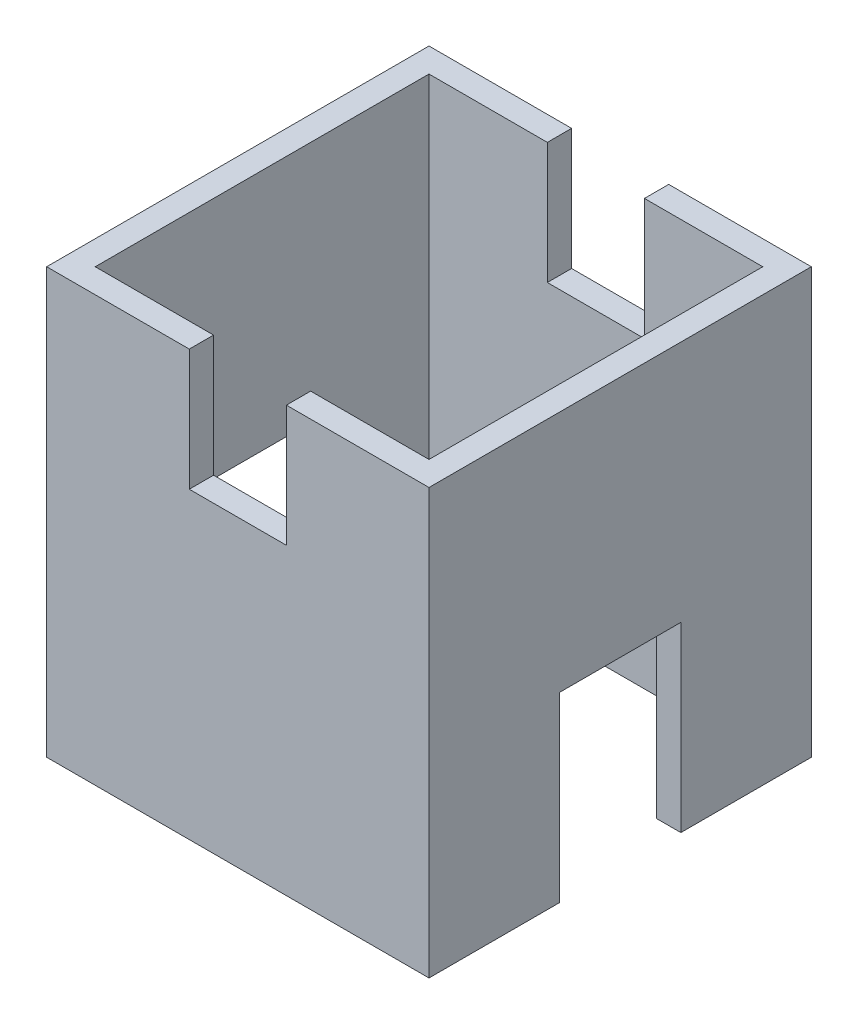
from build123d import *

# Parameters (mm, degrees)
SKETCH1_W           = 31.5
SKETCH1_H           = 31.5
SKETCH1_W_2         = 27.5
SKETCH1_H_2         = 27.5
BOSS_EXTRUDE1_DEPTH = 35
SKETCH2_W           = 10
SKETCH2_H           = 15
CUT_EXTRUDE1_DEPTH  = 32.5
SKETCH3_W           = 8
SKETCH3_H           = 10
CUT_EXTRUDE2_DEPTH  = 32.5


with BuildPart() as part:
    # Sketch1 → Boss-Extrude1 (new body)
    with BuildSketch(Plane(origin=(0, 0, 0), x_dir=(1, 0, 0), z_dir=(0, 1, 0))):
        Rectangle(SKETCH1_W, SKETCH1_H)
        Rectangle(SKETCH1_W_2, SKETCH1_H_2, mode=Mode.SUBTRACT)
    extrude(amount=BOSS_EXTRUDE1_DEPTH)

    # Sketch2 → Cut-Extrude1 (cut, through all)
    with BuildSketch(Plane(origin=(15.75, 0, 0), x_dir=(0, 0, -1), z_dir=(1, 0, 0))):
        with Locations((0, 7.5)):
            Rectangle(SKETCH2_W, SKETCH2_H)
    extrude(amount=-CUT_EXTRUDE1_DEPTH, mode=Mode.SUBTRACT)

    # Sketch3 → Cut-Extrude2 (cut, through all)
    with BuildSketch(Plane(origin=(0, 0, -15.75), x_dir=(-1, 0, 0), z_dir=(0, 0, -1))):
        with Locations((0, 30)):
            Rectangle(SKETCH3_W, SKETCH3_H)
    extrude(amount=-CUT_EXTRUDE2_DEPTH, mode=Mode.SUBTRACT)


solid = part.part
